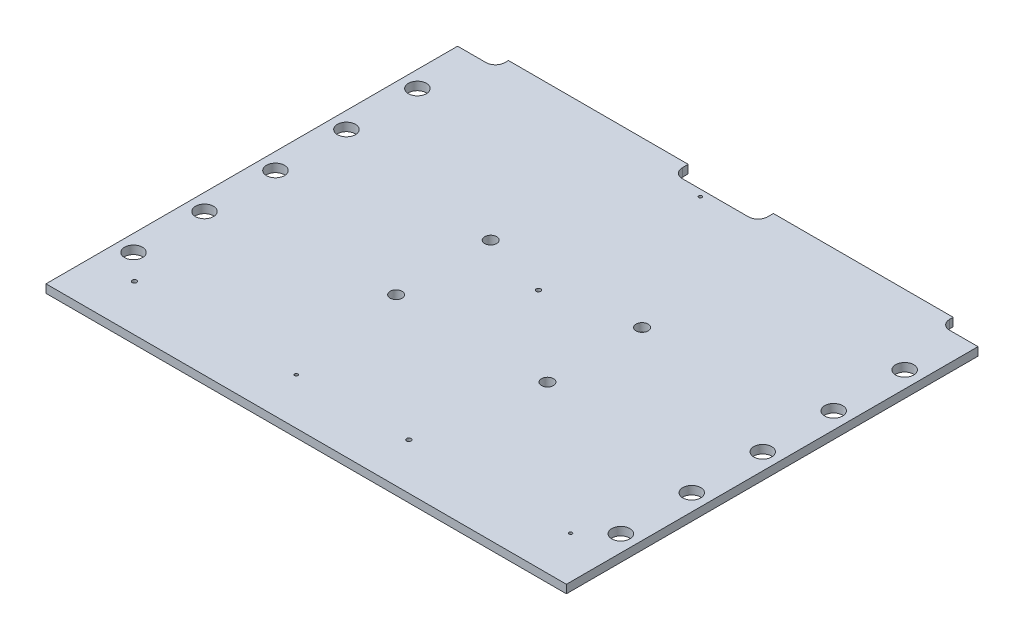
from build123d import *

# Parameters (mm, degrees)
FR4_DEPTH                           = 1.7526
SKETCH7_R                           = 1.905
THERMAL_WALL_HOLES_SIDES_DEPTH      = 2.7526
SKETCH8_R                           = 0.47
SKETCH8_R_2                         = 0.33
CONTROLLED_DEPTH_HOLES_TOP_DEPTH    = 1.1176
SKETCH9_R                           = 0.47
SKETCH9_R_2                         = 0.32
SKETCH9_R_3                         = 0.33
CONTROLLED_DEPTH_HOLES_BOTTOM_DEPTH = 1.1176
SKETCH10_R                          = 1.27
THERMAL_SCREW_HOLES_MIDDLE_DEPTH    = 2.7526


with BuildPart() as part:
    # Sketch1 → FR4 (new body)
    with BuildSketch(Plane(origin=(0, 0, 0), x_dir=(1, 0, 0), z_dir=(0, 1, 0))):
        with BuildLine():
            Line((0, 0), (110, 0))
            Line((110, 0), (110, 87))
            Line((110, 87), (104, 87))
            ThreePointArc((104, 87), (102.585786438, 87.585786438), (102, 89))
            Line((102, 89), (102, 89.75))
            Line((102, 89.75), (64, 89.75))
            Line((64, 89.75), (64, 88.5))
            ThreePointArc((64, 88.5), (63.414213562, 87.085786438), (62, 86.5))
            Line((62, 86.5), (48, 86.5))
            ThreePointArc((48, 86.5), (46.585786438, 87.085786438), (46, 88.5))
            Line((46, 88.5), (46, 89.75))
            Line((46, 89.75), (8, 89.75))
            Line((8, 89.75), (8, 89))
            ThreePointArc((8, 89), (7.414213562, 87.585786438), (6, 87))
            Line((6, 87), (0, 87))
            Line((0, 87), (0, 0))
        make_face()
    extrude(amount=FR4_DEPTH)

    # Sketch7 → thermal-wall-holes-sides (cut, through all)
    with BuildSketch(Plane(origin=(0, 1.7526, 0), x_dir=(1, 0, 0), z_dir=(0, 1, 0))):
        with Locations((3.5, 15)):
            Circle(SKETCH7_R)
        with Locations((106.5, 15)):
            Circle(SKETCH7_R)
        with Locations((106.5, 30)):
            Circle(SKETCH7_R)
        with Locations((106.5, 45)):
            Circle(SKETCH7_R)
        with Locations((106.5, 60)):
            Circle(SKETCH7_R)
        with Locations((106.5, 75)):
            Circle(SKETCH7_R)
        with Locations((3.5, 30)):
            Circle(SKETCH7_R)
        with Locations((3.5, 45)):
            Circle(SKETCH7_R)
        with Locations((3.5, 60)):
            Circle(SKETCH7_R)
        with Locations((3.5, 75)):
            Circle(SKETCH7_R)
    extrude(amount=-THERMAL_WALL_HOLES_SIDES_DEPTH, mode=Mode.SUBTRACT)

    # Sketch8 → controlled-depth-holes.top (cut)
    with BuildSketch(Plane(origin=(0, 1.7526, 0), x_dir=(1, 0, 0), z_dir=(0, 1, 0))):
        with Locations((8.9, 9.8)):
            Circle(SKETCH8_R)
        with Locations((66.9, 9.8)):
            Circle(SKETCH8_R)
        with Locations((53.2, 50.9)):
            Circle(SKETCH8_R)
        with Locations((53.2, 85.1)):
            Circle(SKETCH8_R_2)
        with Locations((43.1, 9.8)):
            Circle(SKETCH8_R_2)
        with Locations((101.1, 9.8)):
            Circle(SKETCH8_R_2)
    extrude(amount=-CONTROLLED_DEPTH_HOLES_TOP_DEPTH, mode=Mode.SUBTRACT)

    # Sketch9 → controlled-depth-holes.bottom (cut)
    with BuildSketch(Plane.XZ):
        with Locations((8.975, -9.5)):
            Circle(SKETCH9_R)
        with Locations((66.975, -9.5)):
            Circle(SKETCH9_R)
        with Locations((53.5, -50.975)):
            Circle(SKETCH9_R)
        with Locations((53.5, -85.175)):
            Circle(SKETCH9_R_2)
        with Locations((43.175, -9.5)):
            Circle(SKETCH9_R_3)
        with Locations((101.175, -9.5)):
            Circle(SKETCH9_R_3)
    extrude(amount=-CONTROLLED_DEPTH_HOLES_BOTTOM_DEPTH, mode=Mode.SUBTRACT)

    # Sketch10 → thermal-screw-holes-middle (cut, through all)
    with BuildSketch(Plane(origin=(0, 1.7526, 0), x_dir=(1, 0, 0), z_dir=(0, 1, 0))):
        with Locations((39, 55)):
            Circle(SKETCH10_R)
        with Locations((71, 55)):
            Circle(SKETCH10_R)
        with Locations((71, 35)):
            Circle(SKETCH10_R)
        with Locations((39, 35)):
            Circle(SKETCH10_R)
    extrude(amount=-THERMAL_SCREW_HOLES_MIDDLE_DEPTH, mode=Mode.SUBTRACT)


solid = part.part
